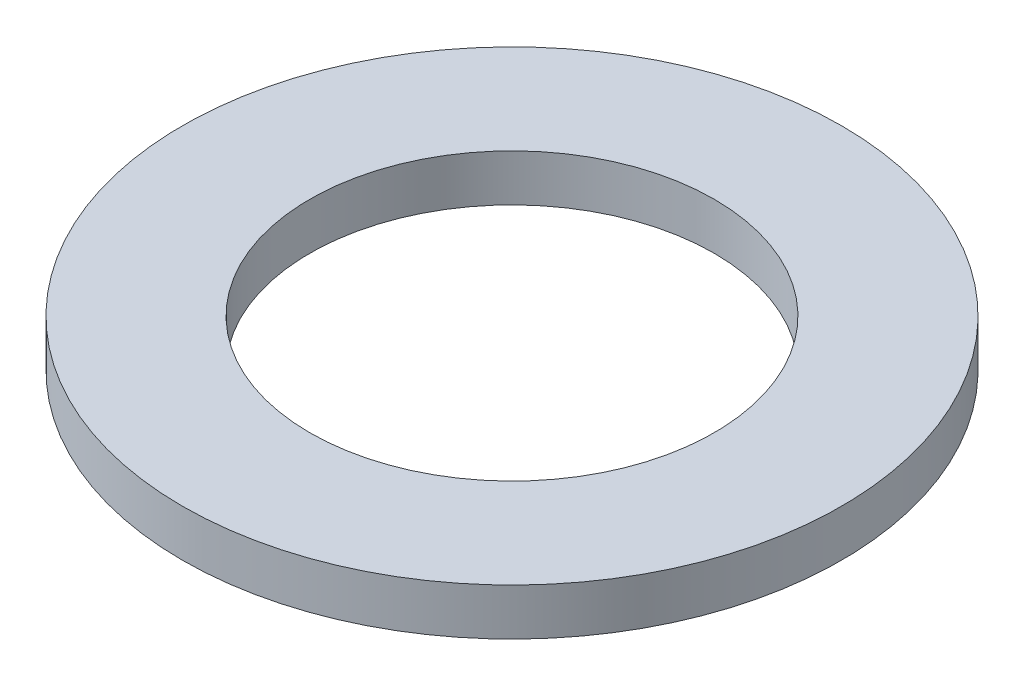
from build123d import *

# Parameters (mm, degrees)
SKETCH1_R           = 5.588
SKETCH1_R_2         = 3.429
BOSS_EXTRUDE1_DEPTH = 0.79375


with BuildPart() as part:
    # Sketch1 → Boss-Extrude1 (new body)
    with BuildSketch(Plane(origin=(0, 0, 0), x_dir=(1, 0, 0), z_dir=(0, 1, 0))):
        Circle(SKETCH1_R)
        Circle(SKETCH1_R_2, mode=Mode.SUBTRACT)
    extrude(amount=BOSS_EXTRUDE1_DEPTH)


solid = part.part
